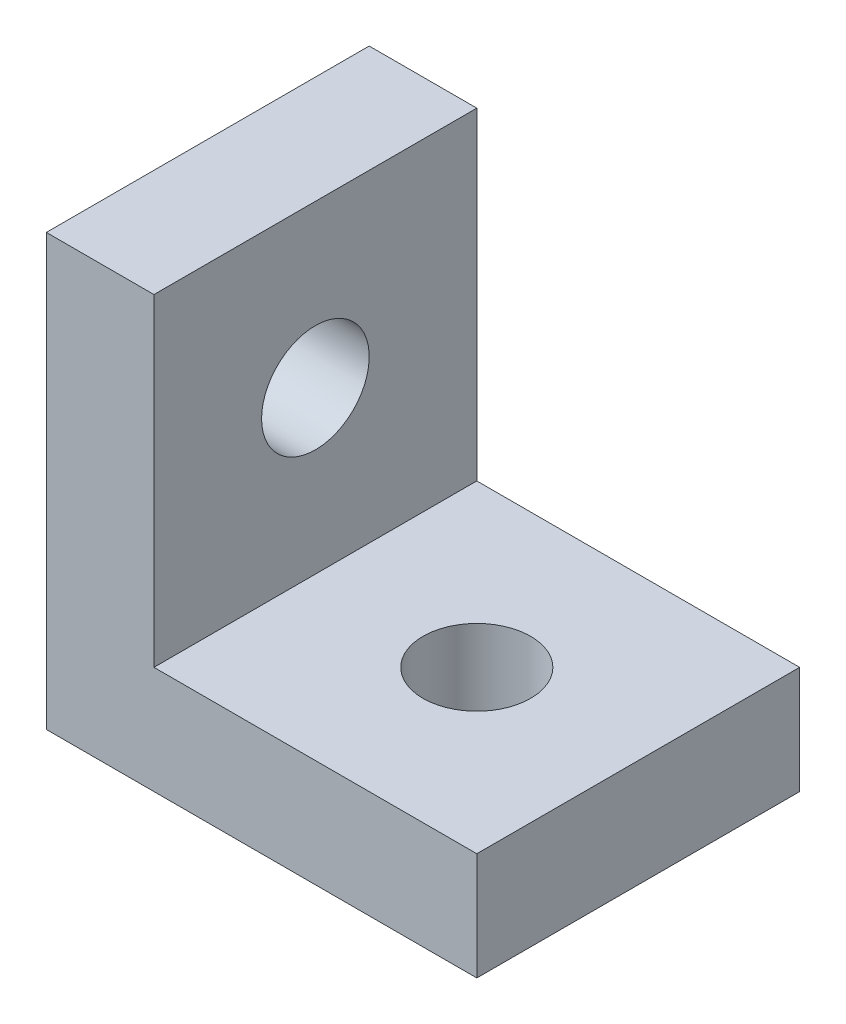
from build123d import *

# Parameters (mm, degrees)
BOSS_EXTRUDE1_DEPTH = 30
SKETCH2_R           = 5
CUT_EXTRUDE1_DEPTH  = 30


with BuildPart() as part:
    # Sketch1 → Boss-Extrude1 (new body)
    with BuildSketch(Plane.XY):
        Polygon((0, 0), (10, 10), (40, 10), (40, 0), align=None)
    extrude(amount=BOSS_EXTRUDE1_DEPTH)

    # Sketch2 → Cut-Extrude1 (cut)
    with BuildSketch(Plane(origin=(0, 10, 0), x_dir=(1, 0, 0), z_dir=(0, 1, 0))):
        with Locations((25, -15)):
            Circle(SKETCH2_R)
    extrude(amount=-CUT_EXTRUDE1_DEPTH, mode=Mode.SUBTRACT)

    # Mirror1: part across plane


with BuildPart() as part_1:
    add(part.part)
    add(part.part.mirror(Plane(origin=(0, 0, 30), x_dir=(0, 0, 1), z_dir=(0.707106781, -0.707106781, 0))))


solid = part_1.part
